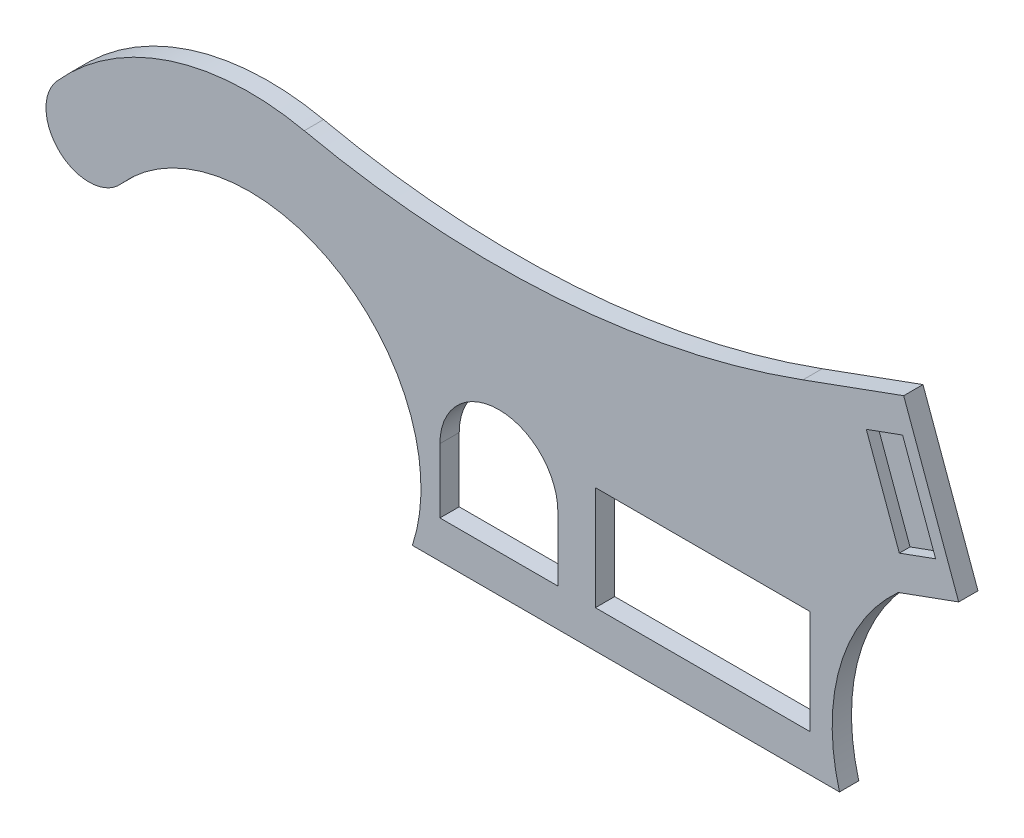
from build123d import *

# Parameters (mm, degrees)
BOSS_EXTRUDE1_DEPTH = 18
SKETCH2_W           = 200
SKETCH2_H           = 97
CUT_EXTRUDE1_DEPTH  = 19
CUT_EXTRUDE2_DEPTH  = 10


with BuildPart() as part:
    # Sketch1 → Boss-Extrude1 (new body)
    with BuildSketch(Plane.XY):
        with BuildLine():
            Line((0, 0), (51.303021499, -140.953893118))
            Line((51.303021499, -140.953893118), (-5.078535748, -161.475101717))
            ThreePointArc((-5.078535748, -161.475101717), (-59.282744504, -247.94612641), (-59.866905015, -350))
            Line((-59.866905015, -350), (-458.18031046, -350))
            ThreePointArc((-458.18031046, -350), (-530.476755656, -161.257646224), (-729.936822659, -193.909350133))
            ThreePointArc((-729.936822659, -193.909350133), (-786.401902791, -197.329105332), (-789.82165799, -140.864025199))
            ThreePointArc((-789.82165799, -140.864025199), (-684.665051265, -71.855170989), (-559.047216388, -65.507458149))
            ThreePointArc((-559.047216388, -65.507458149), (-324.287619955, -82.844559906), (-93.969262079, -34.202014333))
            Line((-93.969262079, -34.202014333), (0, 0))
        make_face()
    extrude(amount=BOSS_EXTRUDE1_DEPTH)

    # Sketch2 → Cut-Extrude1 (cut, through all)
    with BuildSketch(Plane.XY.offset(18)):
        with Locations((-187.508312236, -266.5)):
            Rectangle(SKETCH2_W, SKETCH2_H)
        with BuildLine():
            Line((-322.508312236, -315), (-432.508312236, -315))
            Line((-432.508312236, -315), (-432.508312236, -255))
            ThreePointArc((-432.508312236, -255), (-377.508312236, -200), (-322.508312236, -255))
            Line((-322.508312236, -255), (-322.508312236, -315))
        make_face()
    extrude(amount=-CUT_EXTRUDE1_DEPTH, mode=Mode.SUBTRACT)

    # Sketch3 → Cut-Extrude2 (cut)
    with BuildSketch(Plane.XY.offset(18)):
        Polygon((-1.01570715, -32.295020343), (29.76610575, -116.867356214), (-4.062828599, -129.180081374), (-34.844641498, -44.607745503), align=None)
    extrude(amount=-CUT_EXTRUDE2_DEPTH, mode=Mode.SUBTRACT)


solid = part.part
